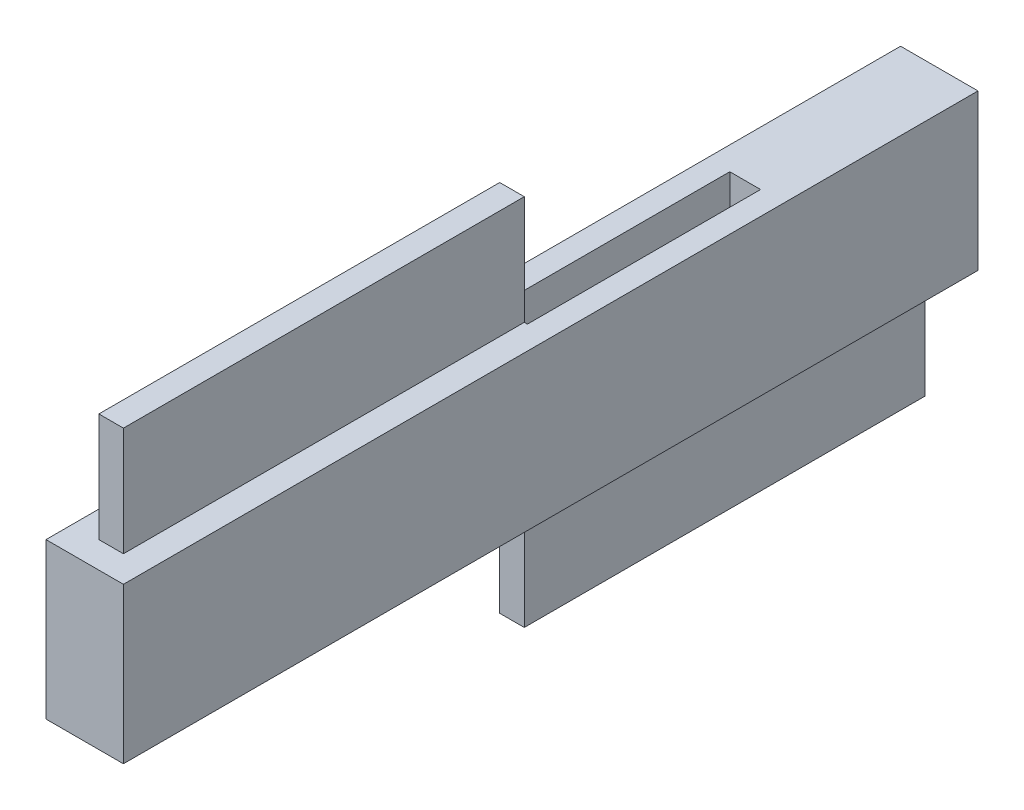
from build123d import *

# Parameters (mm, degrees)
SKETCH1_W           = 4.980670257
SKETCH1_H           = 54.9718421
BOSS_EXTRUDE1_DEPTH = 10
SKETCH2_W           = 1.980670257
SKETCH2_H           = 15
CUT_EXTRUDE2_DEPTH  = 7
SKETCH4_W           = 1.980670257
SKETCH4_H           = 25.98592105
CUT_EXTRUDE3_DEPTH  = 7
SKETCH5_W           = 1.580670257
SKETCH5_H           = 25.78592105
BOSS_EXTRUDE2_DEPTH = 7
SKETCH6_W           = 1.580670257
SKETCH6_H           = 25.78592105
BOSS_EXTRUDE3_DEPTH = 7


with BuildPart() as part:
    # Sketch1 → Boss-Extrude1 (new body)
    with BuildSketch(Plane(origin=(0, 0, 0), x_dir=(1, 0, 0), z_dir=(0, 1, 0))):
        with Locations((-11.806033203, 3.043742935)):
            Rectangle(SKETCH1_W, SKETCH1_H)
    extrude(amount=BOSS_EXTRUDE1_DEPTH)

    # Sketch2 → Cut-Extrude2 (cut)
    with BuildSketch(Plane(origin=(0, 10, 0), x_dir=(1, 0, 0), z_dir=(0, 1, 0))):
        with Locations((-11.806033203, 10.543742935)):
            Rectangle(SKETCH2_W, SKETCH2_H)
    extrude(amount=-CUT_EXTRUDE2_DEPTH, mode=Mode.SUBTRACT)

    # Sketch4 → Cut-Extrude3 (cut)
    with BuildSketch(Plane.XZ):
        with Locations((-11.806033203, 9.94921759)):
            Rectangle(SKETCH4_W, SKETCH4_H)
    extrude(amount=-CUT_EXTRUDE3_DEPTH, mode=Mode.SUBTRACT)

    # Sketch5 → Boss-Extrude2 (add)
    with BuildSketch(Plane.XZ):
        with Locations((-11.806033203, -15.93670346)):
            Rectangle(SKETCH5_W, SKETCH5_H)
    extrude(amount=BOSS_EXTRUDE2_DEPTH)

    # Sketch6 → Boss-Extrude3 (add)
    with BuildSketch(Plane(origin=(0, 10, 0), x_dir=(1, 0, 0), z_dir=(0, 1, 0))):
        with Locations((-11.806033203, -9.84921759)):
            Rectangle(SKETCH6_W, SKETCH6_H)
    extrude(amount=BOSS_EXTRUDE3_DEPTH)


solid = part.part
